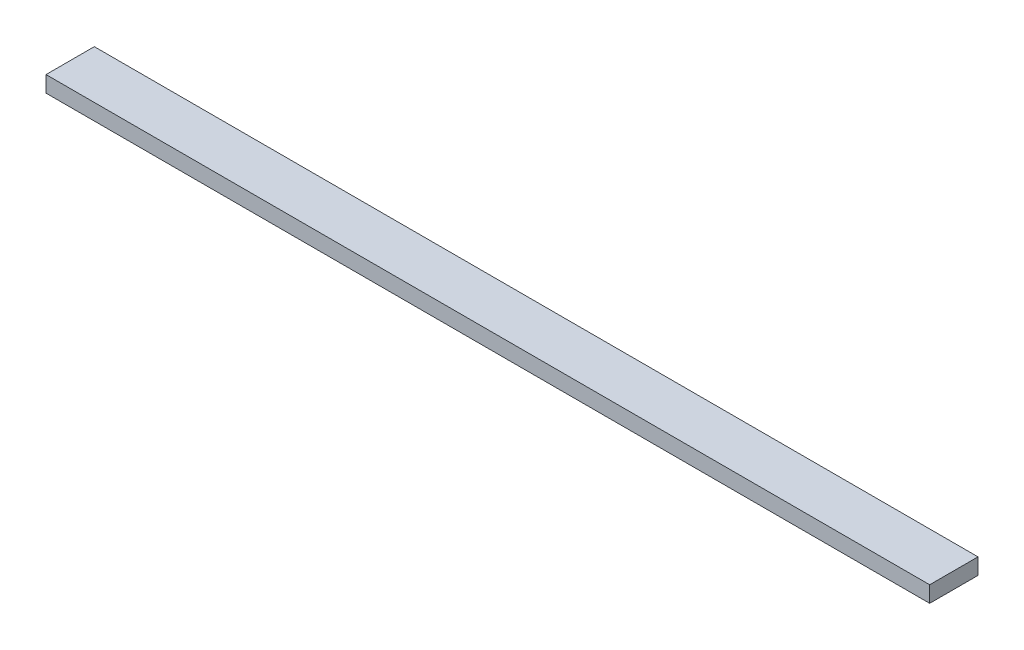
from build123d import *

# Parameters (mm, degrees)
SKETCH1_W           = 548.53
SKETCH1_H           = 30
BOSS_EXTRUDE1_DEPTH = 10


with BuildPart() as part:
    # Sketch1 → Boss-Extrude1 (new body)
    with BuildSketch(Plane(origin=(0, 0, 0), x_dir=(1, 0, 0), z_dir=(0, 1, 0))):
        Rectangle(SKETCH1_W, SKETCH1_H)
    extrude(amount=BOSS_EXTRUDE1_DEPTH)


solid = part.part
